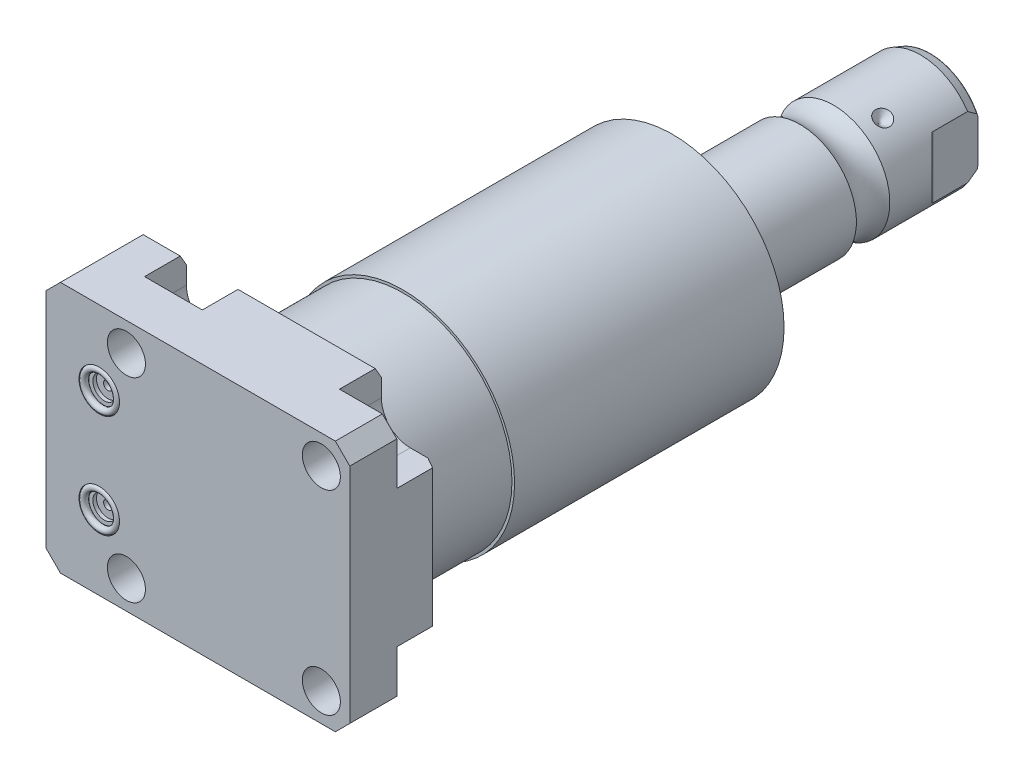
from build123d import *

# Parameters (mm, degrees)
SKETCH1_W               = 85.496
SKETCH1_H               = 70.866
EXTRUDE1_DEPTH          = 25.019
HOLE1_D                 = 10.719
CUT_EXTRUDE2_DEPTH      = 11.786
SKETCH6_R               = 5.7023
CUT_EXTRUDE3_DEPTH      = 1.4478
SKETCH7_R               = 3.2512
CUT_EXTRUDE4_DEPTH      = 1.016
SKETCH8_R               = 1.2446
CUT_EXTRUDE5_DEPTH      = 11.9888
SKETCH9_R               = 0.9271
CHAMFER1_SIZE           = 4.064
CHAMFER2_SIZE           = 3.0226
CHAMFER2_SIZE2          = 1.745098924
CIRPATTERN1_COUNT       = 3
FILLET2_R               = 0.635
CUT_EXTRUDE8_DEPTH      = 36.433
CUT_EXTRUDE8_DEPTH_BACK = 36.433


with BuildPart() as part:
    # Sketch1 → Extrude1 (new body)
    with BuildSketch(Plane.XY):
        with Locations((-7.315, 0)):
            Rectangle(SKETCH1_W, SKETCH1_H)
    extrude(amount=EXTRUDE1_DEPTH)

    # Hole1 (through all)
    with Locations(Plane(origin=(0, 0, 0), x_dir=(-1, 0, 0), z_dir=(0, 0, -1))):
        with Locations((-27.432, -27.432), (-27.432, 27.432), (27.432, 27.432), (27.432, -27.432)):
            Hole(HOLE1_D / 2)

    # Sketch3 → Cut-Extrude2 (cut)
    with BuildSketch(Plane(origin=(0, 0, 0), x_dir=(-1, 0, 0), z_dir=(0, 0, -1))):
        with BuildLine():
            Line((-27.432, -19.304), (-35.433, -19.304))
            Line((-35.433, -19.304), (-35.433, -35.433))
            Line((-35.433, -35.433), (-19.304, -35.433))
            Line((-19.304, -35.433), (-19.304, -27.432))
            ThreePointArc((-19.304, -27.432), (-21.684636083, -21.684636083), (-27.432, -19.304))
        make_face()
        with BuildLine():
            Line((-35.433, 19.304), (-35.433, 35.433))
            Line((-35.433, 35.433), (-19.304, 35.433))
            Line((-19.304, 35.433), (-19.304, 27.432))
            ThreePointArc((-19.304, 27.432), (-21.684636083, 21.684636083), (-27.432, 19.304))
            Line((-27.432, 19.304), (-35.433, 19.304))
        make_face()
        with BuildLine():
            Line((19.304, 35.433), (19.304, 27.432))
            ThreePointArc((19.304, 27.432), (27.432, 19.304), (35.56, 27.432))
            Line((35.56, 27.432), (35.56, 35.433))
            Line((35.56, 35.433), (19.304, 35.433))
        make_face()
        with BuildLine():
            Line((35.56, -35.433), (19.304, -35.433))
            Line((19.304, -35.433), (19.304, -27.432))
            ThreePointArc((19.304, -27.432), (27.432, -19.304), (35.56, -27.432))
            Line((35.56, -27.432), (35.56, -35.433))
        make_face()
    extrude(amount=-CUT_EXTRUDE2_DEPTH, mode=Mode.SUBTRACT)

    # Sketch23 → Cut-Revolve5 (revolve, cut)
    with BuildSketch(Plane.XY.offset(12.522), mode=Mode.PRIVATE) as cut_revolve5_sk:
        Polygon((-50.063, -23.749), (-49.809, -23.749), (-49.809, -19.6596), (-49.0978, -18.9484), (-35.6358, -18.9484), (-35.6358, -13.0048), (-50.063, -13.0048), align=None)
    cut_revolve5 = revolve(cut_revolve5_sk.sketch.rotate(Axis((-11.939660979, -13.0048, 12.522), (-1, 0, 0)), 180), axis=Axis((-11.939660979, -13.0048, 12.522), (-1, 0, 0)), mode=Mode.SUBTRACT)  # turned: the seam where the file's is

    # Mirror1: Cut-Revolve5 across plane
    add(cut_revolve5.mirror(Plane.ZX), mode=Mode.SUBTRACT)

    # Sketch6 → Cut-Extrude3 (cut)
    with BuildSketch(Plane.XY.offset(25.019)):
        with Locations((-35.077, -14.529)):
            Circle(SKETCH6_R)
        with Locations((-35.077, 14.529)):
            Circle(SKETCH6_R)
    extrude(amount=-CUT_EXTRUDE3_DEPTH, mode=Mode.SUBTRACT)

    # Sketch7 → Cut-Extrude4 (cut)
    with BuildSketch(Plane.XY.offset(23.5712)):
        with Locations((-35.077, 14.529)):
            Circle(SKETCH7_R)
        with Locations((-35.077, -14.529)):
            Circle(SKETCH7_R)
    extrude(amount=-CUT_EXTRUDE4_DEPTH, mode=Mode.SUBTRACT)

    # Sketch8 → Cut-Extrude5 (cut)
    with BuildSketch(Plane.XY.offset(22.5552)):
        with Locations((-35.077, 14.529)):
            Circle(SKETCH8_R)
        with Locations((-35.077, -14.529)):
            Circle(SKETCH8_R)
    extrude(amount=-CUT_EXTRUDE5_DEPTH, mode=Mode.SUBTRACT)

    # Chamfer1
    chamfer1_edges = [part.edges().sort_by_distance(p)[0] for p in [
        (-50.063, 35.433, 12.5095),
        (35.433, 35.433, 18.4025),
        (35.433, -35.433, 18.4025),
        (-50.063, -35.433, 12.5095),
    ]]
    chamfer(chamfer1_edges, length=CHAMFER1_SIZE)

    # Chamfer2
    chamfer2_edges = [part.edges().sort_by_distance(p)[0] for p in [
        (-40.7795, -35.433, 0),
        (35.433, 0, 0),
        (0, 35.433, 0),
        (-40.7795, 35.433, 0),
        (0, -35.433, 0),
    ]]
    chamfer2_side = [part.faces().sort_by_distance(p)[0] for p in [
        (-8.721219411, 0, 0),
    ]]
    chamfer(chamfer2_edges, length=CHAMFER2_SIZE, length2=CHAMFER2_SIZE2, reference=chamfer2_side[0])

    # Sketch24 → Revolve4 (revolve)
    with BuildSketch(Plane(origin=(0, 0, 0), x_dir=(0, 0, -1), z_dir=(1, 0, 0)), mode=Mode.PRIVATE) as revolve4_sk:
        Polygon((0, 0), (0, 30.658), (25.4, 30.658), (25.4, 31.3945), (101.242301194, 31.3945), (104.55, 19.05), (104.55, 0), align=None)
    revolve(revolve4_sk.sketch.rotate(Axis((0, 0, 0), (0, 0, -1)), 90), axis=Axis((0, 0, 0), (0, 0, -1)))  # turned: the seam where the file's is

    # Sketch17 → Revolve3 (revolve)
    with BuildSketch(Plane(origin=(0, 0, 0), x_dir=(0, 0, -1), z_dir=(1, 0, 0)), mode=Mode.PRIVATE) as revolve3_sk:
        with BuildLine():
            Line((104.55, 0), (104.55, -15.875))
            Line((104.55, -15.875), (137.117705156, -15.875))
            ThreePointArc((137.117705156, -15.875), (141.825, -14.3255), (146.532294844, -15.875))
            Line((146.532294844, -15.875), (171.00999416, -15.875))
            Line((171.00999416, -15.875), (173.931, -14.81184082))
            Line((173.931, -14.81184082), (173.931, 0))
            Line((173.931, 0), (104.55, 0))
        make_face()
    revolve(revolve3_sk.sketch.rotate(Axis((0, 0, -130.8989), (0, 0, 1)), 270), axis=Axis((0, 0, -130.8989), (0, 0, 1)))  # turned: the seam where the file's is

    # Sketch30 → Cut-Revolve6 (revolve, cut)
    with BuildSketch(Plane(origin=(0, 0, 0), x_dir=(1, 0, 0), z_dir=(0, 1, 0)), mode=Mode.PRIVATE) as cut_revolve6_sk:
        Polygon((-15.875, 154.906), (-13.462, 152.493), (-15.875, 152.493), align=None)
    cut_revolve6 = revolve(cut_revolve6_sk.sketch.rotate(Axis((-27.819320819, 0, -152.493), (1, 0, 0)), 180), axis=Axis((-27.819320819, 0, -152.493), (1, 0, 0)), mode=Mode.SUBTRACT)  # turned: the seam where the file's is

    # CirPattern1: Cut-Revolve6 ×3 about axis
    cirpattern1_axis = Axis((0, 0, -130.8989), (0, 0, -1))
    for i in range(1, CIRPATTERN1_COUNT):
        add(cut_revolve6.rotate(cirpattern1_axis, i * 360 / CIRPATTERN1_COUNT), mode=Mode.SUBTRACT)

    # Fillet2
    fillet2_edges = [part.edges().sort_by_distance(p)[0] for p in [
        (14.81184082, 0, -173.931),
    ]]
    fillet(fillet2_edges, radius=FILLET2_R)

    # Sketch32 → Cut-Extrude8 (cut, two sides)
    with BuildSketch(Plane(origin=(0, 0, 0), x_dir=(1, 0, 0), z_dir=(0, 1, 0))) as cut_extrude8_sk:
        with BuildLine():
            Line((-13.284, 173.931), (-13.284, 161.231))
            ThreePointArc((-13.284, 161.231), (-13.342003912, 160.939394643), (-13.507185078, 160.692183558))
            Line((-13.507185078, 160.692183558), (-15.875, 158.324368636))
            Line((-15.875, 158.324368636), (-15.875, 173.931))
            Line((-15.875, 173.931), (-13.284, 173.931))
        make_face()
        with BuildLine():
            Line((15.875, 173.931), (13.284, 173.931))
            Line((13.284, 173.931), (13.284, 161.231))
            ThreePointArc((13.284, 161.231), (13.342003912, 160.939394643), (13.507185078, 160.692183558))
            Line((13.507185078, 160.692183558), (15.875, 158.324368636))
            Line((15.875, 158.324368636), (15.875, 173.931))
        make_face()
    extrude(amount=CUT_EXTRUDE8_DEPTH, mode=Mode.SUBTRACT)
    extrude(cut_extrude8_sk.sketch, amount=-CUT_EXTRUDE8_DEPTH_BACK, mode=Mode.SUBTRACT)

    # Sketch33 → Hole2 (revolve, cut)
    with BuildSketch(Plane(origin=(0, 0, -173.931), x_dir=(0, 1, 0), z_dir=(1, 0, 0))):
        Polygon((0, 0), (0, 29.566487704), (6.9342, 25.4), (6.9342, 0), align=None)
    revolve(axis=Axis((0, 0, -178.175199587), (0, 0, 1)), mode=Mode.SUBTRACT)


with BuildPart() as body_2:
    # Sketch9 → Revolve1 (revolve)
    with BuildSketch(Plane(origin=(-41.656, 14.5288, 23.5712), x_dir=(1, 0, 0), z_dir=(0, 1, 0))):
        with Locations((11.3542, -0.9271)):
            Circle(SKETCH9_R)
    revolve(axis=Axis((-35.077, 14.5288, 25.51811), (0, 0, -1)))


with BuildPart() as body_3:
    # Mirror2: mirrored copy
    add(body_2.part.mirror(Plane.ZX))


solid = Compound([part.part, body_2.part, body_3.part])
